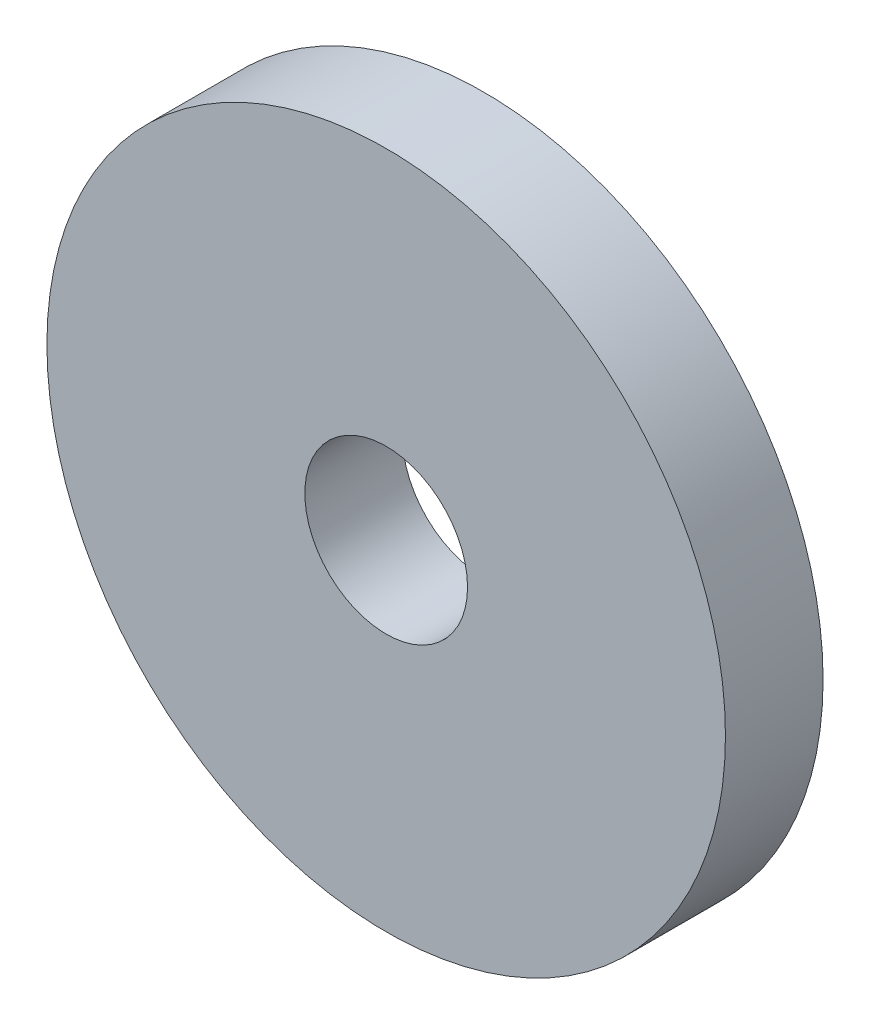
from build123d import *

# Parameters (mm, degrees)
SKETCH1_R           = 104.25
SKETCH1_R_2         = 25
BOSS_EXTRUDE1_DEPTH = 30


with BuildPart() as part:
    # Sketch1 → Boss-Extrude1 (new body)
    with BuildSketch(Plane.XY):
        Circle(SKETCH1_R)
        Circle(SKETCH1_R_2, mode=Mode.SUBTRACT)
    extrude(amount=BOSS_EXTRUDE1_DEPTH)


solid = part.part
